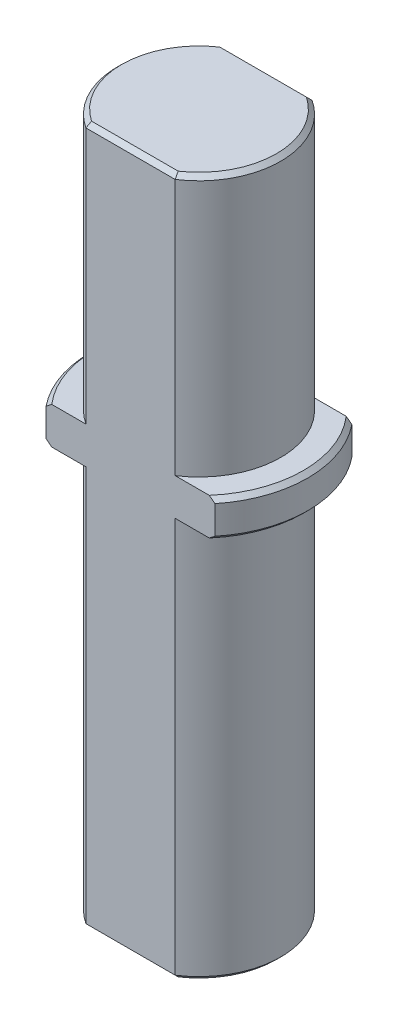
from build123d import *

# Parameters (mm, degrees)
BOSS_EXTRUDE1_DEPTH = 64.2
CHAMFER1_SIZE       = 0.4
BOSS_EXTRUDE2_DEPTH = 3.4
CHAMFER2_SIZE       = 0.4


with BuildPart() as part:
    # Sketch1 → Boss-Extrude1 (new body)
    with BuildSketch(Plane(origin=(0, 0, 0), x_dir=(1, 0, 0), z_dir=(0, 1, 0))):
        with BuildLine():
            Line((-4.106141741, -6.3), (4.106141741, -6.3))
            ThreePointArc((4.106141741, -6.3), (7.52, 0), (4.106141741, 6.3))
            Line((4.106141741, 6.3), (-4.106141741, 6.3))
            ThreePointArc((-4.106141741, 6.3), (-7.52, 0), (-4.106141741, -6.3))
        make_face()
    extrude(amount=BOSS_EXTRUDE1_DEPTH)

    # Chamfer1
    chamfer1_edges = [part.edges().sort_by_distance(p)[0] for p in [
        (7.52, 64.2, 0),
        (0, 64.2, -6.3),
        (-7.52, 64.2, 0),
        (-7.52, 0, 0),
        (0, 64.2, 6.3),
        (0, 0, -6.3),
        (7.52, 0, 0),
        (0, 0, 6.3),
    ]]
    chamfer(chamfer1_edges, length=CHAMFER1_SIZE)

    # Sketch2 → Boss-Extrude2 (add)
    with BuildSketch(Plane(origin=(0, 40.2, 0), x_dir=(1, 0, 0), z_dir=(0, 1, 0))):
        with BuildLine():
            Line((-7.765951326, -6.3), (7.765951326, -6.3))
            ThreePointArc((7.765951326, -6.3), (10, 0), (7.765951326, 6.3))
            Line((7.765951326, 6.3), (-7.765951326, 6.3))
            ThreePointArc((-7.765951326, 6.3), (-10, 0), (-7.765951326, -6.3))
        make_face()
    extrude(amount=-BOSS_EXTRUDE2_DEPTH)

    # Chamfer2
    chamfer2_edges = [part.edges().sort_by_distance(p)[0] for p in [
        (10, 40.2, 0),
        (-10, 36.8, 0),
        (10, 36.8, 0),
        (-10, 40.2, 0),
    ]]
    chamfer(chamfer2_edges, length=CHAMFER2_SIZE)


solid = part.part
